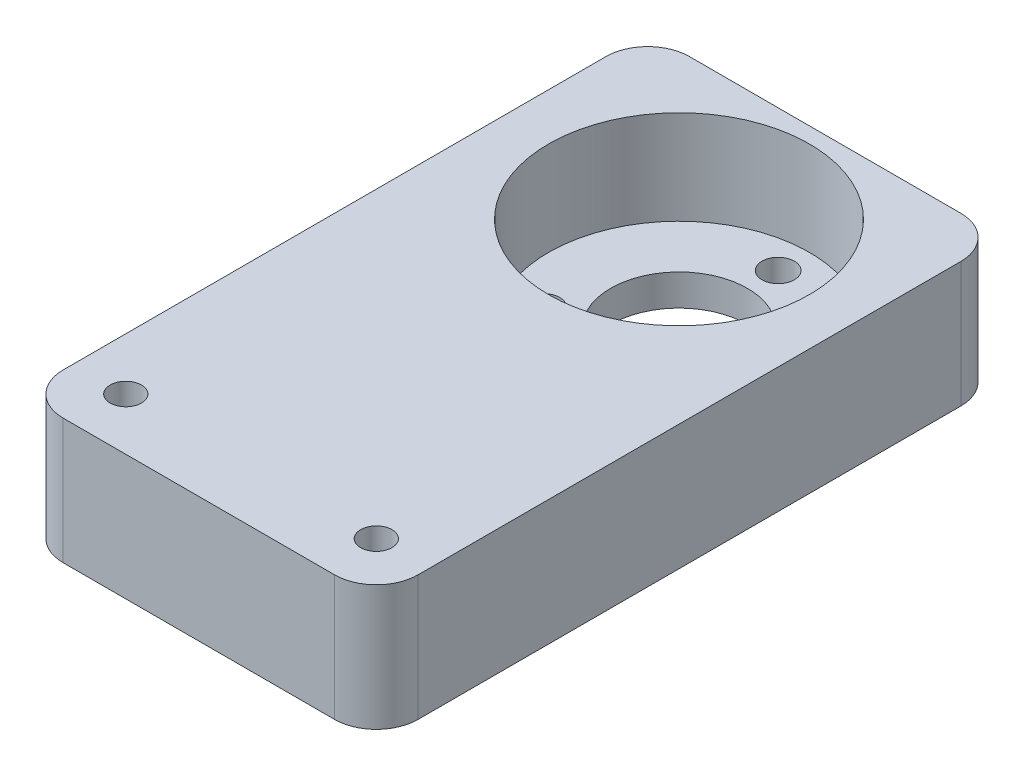
from build123d import *

# Parameters (mm, degrees)
SKETCH_1_W             = 34
SKETCH_1_H             = 60
EXTRUDE_443_DEPTH      = 12
SKETCH_2_R             = 2.1
CUT_EXTRUDE_710_DEPTH  = 13
SKETCH_3_R             = 12.5
CUT_EXTRUDE_893_DEPTH  = 9
SKETCH_4_R             = 6.55
CUT_EXTRUDE_999_DEPTH  = 4
SKETCH_5_R             = 1.55
CUT_EXTRUDE_1168_DEPTH = 4
FILLET_4_R             = 4
SKETCH_6_R             = 2.1
SKETCH_6_R_2           = 1.5
EXTRUDE_1_DEPTH        = 12


with BuildPart() as part:
    # 草图1 → Extrude 443 (new body)
    with BuildSketch(Plane(origin=(0, 0, 0), x_dir=(1, 0, 0), z_dir=(0, 1, 0))):
        Rectangle(SKETCH_1_W, SKETCH_1_H)
    extrude(amount=EXTRUDE_443_DEPTH)

    # 草图2 → Cut-Extrude 710 (cut, through all)
    with BuildSketch(Plane(origin=(0, 12, 0), x_dir=(1, 0, 0), z_dir=(0, 1, 0))):
        with Locations((-12, -25)):
            Circle(SKETCH_2_R)
        with Locations((12, -25)):
            Circle(SKETCH_2_R)
    extrude(amount=-CUT_EXTRUDE_710_DEPTH, mode=Mode.SUBTRACT)

    # 草图3 → Cut-Extrude 893 (cut)
    with BuildSketch(Plane(origin=(0, 12, 0), x_dir=(1, 0, 0), z_dir=(0, 1, 0))):
        with Locations((0, 16)):
            Circle(SKETCH_3_R)
    extrude(amount=-CUT_EXTRUDE_893_DEPTH, mode=Mode.SUBTRACT)

    # 草图4 → Cut-Extrude 999 (cut, through all)
    with BuildSketch(Plane(origin=(0, 3, 0), x_dir=(1, 0, 0), z_dir=(0, 1, 0))):
        with Locations((0, 16)):
            Circle(SKETCH_4_R)
    extrude(amount=-CUT_EXTRUDE_999_DEPTH, mode=Mode.SUBTRACT)

    # 草图5 → Cut-Extrude 1168 (cut, through all)
    with BuildSketch(Plane(origin=(0, 3, 0), x_dir=(1, 0, 0), z_dir=(0, 1, 0))):
        with Locations((0, 25.5)):
            Circle(SKETCH_5_R)
        with Locations((8.227241336, 11.25)):
            Circle(SKETCH_5_R)
        with Locations((-8.227241336, 11.25)):
            Circle(SKETCH_5_R)
    extrude(amount=-CUT_EXTRUDE_1168_DEPTH, mode=Mode.SUBTRACT)

    # 圆角4
    fillet_4_edges = [part.edges().sort_by_distance(p)[0] for p in [
        (17, 6, 30),
        (-17, 6, 30),
        (-17, 6, -30),
        (17, 6, -30),
    ]]
    fillet(fillet_4_edges, radius=FILLET_4_R)

    # 草图6 → 凸台-拉伸1 (add)
    with BuildSketch(Plane(origin=(0, 12, 0), x_dir=(1, 0, 0), z_dir=(0, 1, 0))):
        with Locations((-12, -25)):
            Circle(SKETCH_6_R)
        with Locations((-12, -25)):
            Circle(SKETCH_6_R_2, mode=Mode.SUBTRACT)
        with Locations((12, -25)):
            Circle(SKETCH_6_R)
        with Locations((12, -25)):
            Circle(SKETCH_6_R_2, mode=Mode.SUBTRACT)
    extrude(amount=-EXTRUDE_1_DEPTH)


solid = part.part
